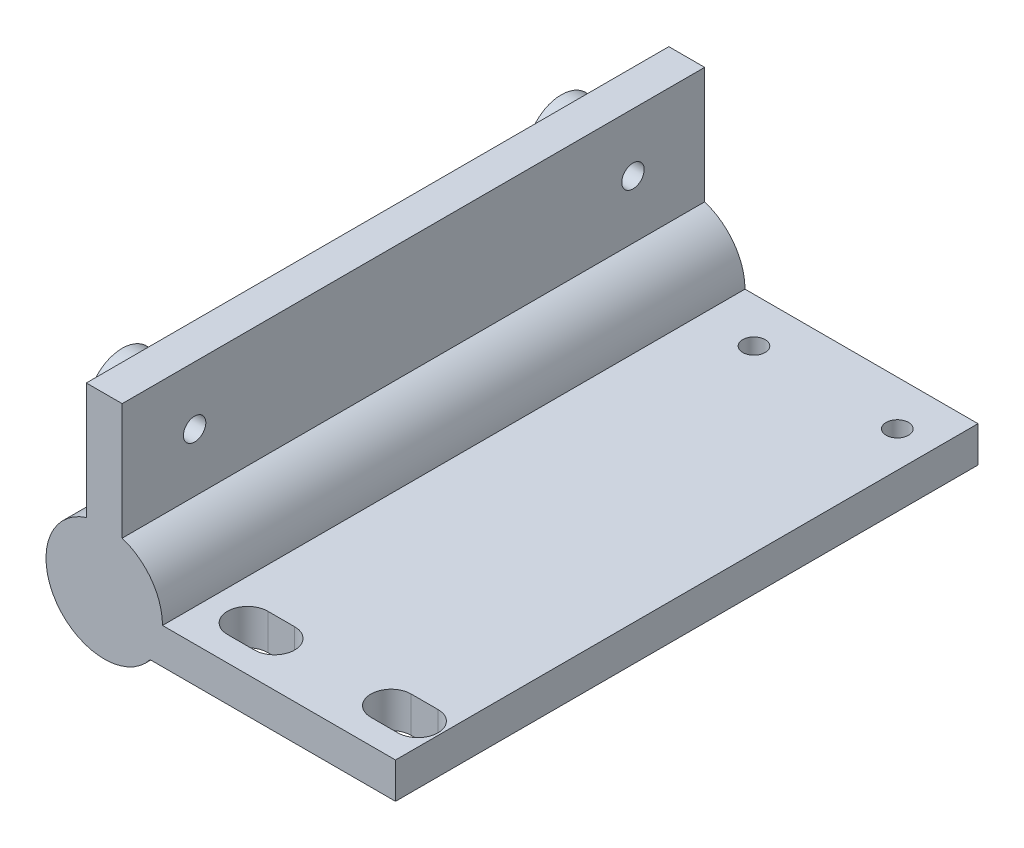
from build123d import *

# Parameters (mm, degrees)
SKETCH_1_R          = 4.1
EXTRUDE_1_DEPTH     = 65
SKETCH_2_R          = 4.923200542
EXTRUDE_2_DEPTH     = 3
SKETCH_3_R          = 1.25
CUT_EXTRUDE_1_DEPTH = 13
SKETCH_4_R          = 3.85
EXTRUDE_3_DEPTH     = 4
SKETCH_5_R          = 1.25
CUT_EXTRUDE_2_DEPTH = 14


with BuildPart() as part:
    # Эскиз1 → Бобышка-Вытянуть1 (new body)
    with BuildSketch(Plane.XY):
        with BuildLine():
            Line((5.123475383, -4), (32.5, -4))
            Line((32.5, -4), (32.5, 0))
            Line((32.5, 0), (6.5, 0))
            ThreePointArc((6.5, 0), (5.25594901, 3.824264635), (2, 6.184658438))
            Line((2, 6.184658438), (2, 19.184658438))
            Line((2, 19.184658438), (-2, 19.184658438))
            Line((-2, 19.184658438), (-2, 6.184658438))
            ThreePointArc((-2, 6.184658438), (-5.326428587, -3.725474266), (5.123475383, -4))
        make_face()
        Circle(SKETCH_1_R, mode=Mode.SUBTRACT)
    extrude(amount=EXTRUDE_1_DEPTH)

    # Эскиз2 → Бобышка-Вытянуть2 (add)
    with BuildSketch(Plane.XY.offset(65)):
        Circle(SKETCH_2_R)
    extrude(amount=-EXTRUDE_2_DEPTH)

    # Эскиз3 → Вырез-Вытянуть1 (cut)
    with BuildSketch(Plane(origin=(0, 0, 0), x_dir=(1, 0, 0), z_dir=(0, 1, 0))):
        with Locations((12.5, -5)):
            Circle(SKETCH_3_R)
        with Locations((28.5, -5)):
            Circle(SKETCH_3_R)
        with BuildLine():
            Line((27, -57.75), (30, -57.75))
            ThreePointArc((30, -57.75), (32.25, -60), (30, -62.25))
            Line((30, -62.25), (27, -62.25))
            ThreePointArc((27, -62.25), (24.75, -60), (27, -57.75))
        make_face()
        with BuildLine():
            Line((11, -57.75), (14, -57.75))
            ThreePointArc((14, -57.75), (16.25, -60), (14, -62.25))
            Line((14, -62.25), (11, -62.25))
            ThreePointArc((11, -62.25), (8.75, -60), (11, -57.75))
        make_face()
    extrude(amount=-CUT_EXTRUDE_1_DEPTH, mode=Mode.SUBTRACT)

    # Эскиз4 → Бобышка-Вытянуть3 (add)
    with BuildSketch(Plane.ZY.offset(2)):
        with Locations((8, 12.684658438)):
            Circle(SKETCH_4_R)
        with Locations((57, 12.684658438)):
            Circle(SKETCH_4_R)
    extrude(amount=EXTRUDE_3_DEPTH)

    # Эскиз5 → Вырез-Вытянуть2 (cut)
    with BuildSketch(Plane.ZY.offset(6)):
        with Locations((8, 12.684658438)):
            Circle(SKETCH_5_R)
        with Locations((56.916589889, 12.684658438)):
            Circle(SKETCH_5_R)
    extrude(amount=-CUT_EXTRUDE_2_DEPTH, mode=Mode.SUBTRACT)


solid = part.part
